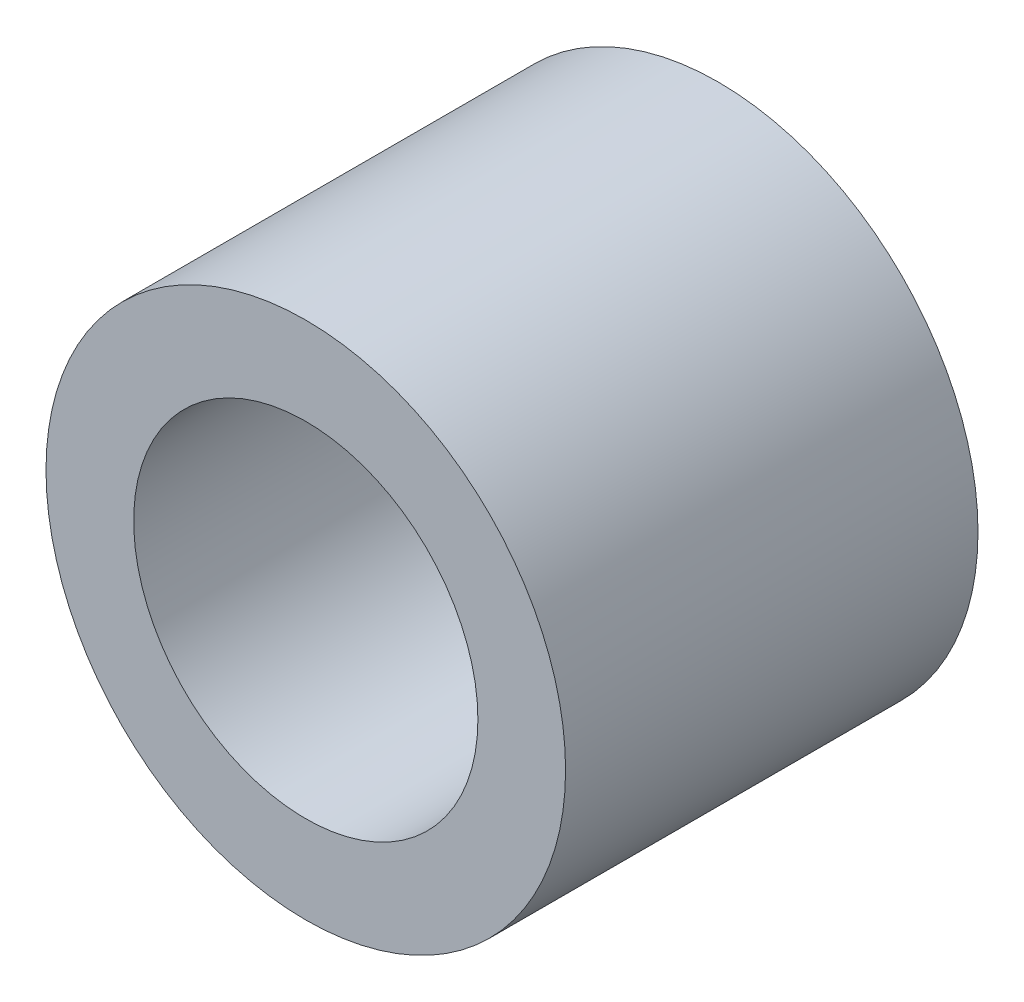
from build123d import *

# Parameters (mm, degrees)
SKETCH1_R      = 4
SKETCH1_R_2    = 2.65
EXTRUDE1_DEPTH = 3.175


with BuildPart() as part:
    # Sketch1 → Extrude1 (new body, symmetric)
    with BuildSketch(Plane.XY):
        Circle(SKETCH1_R)
        Circle(SKETCH1_R_2, mode=Mode.SUBTRACT)
    extrude(amount=EXTRUDE1_DEPTH, both=True)


solid = part.part
